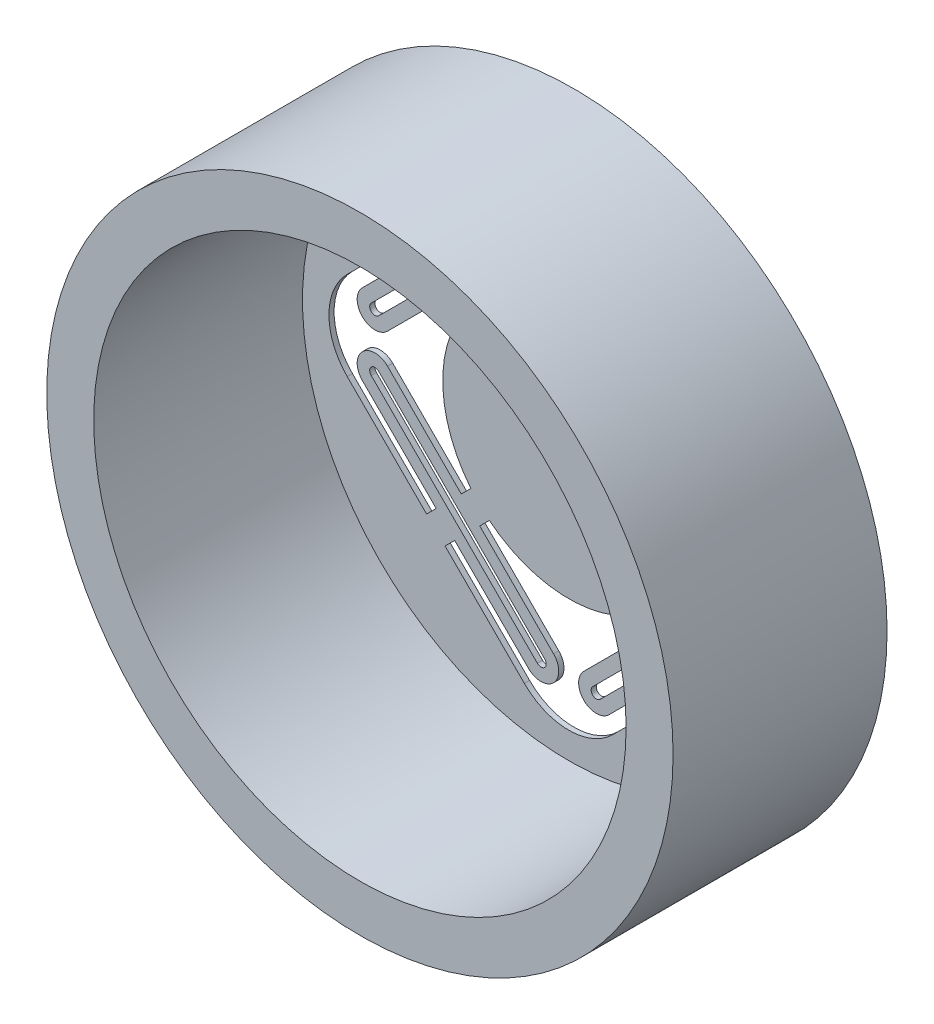
from build123d import *

# Parameters (mm, degrees)
SKETCH1_R           = 15
SKETCH1_R_2         = 12.75
BOSS_EXTRUDE1_DEPTH = 10
SKETCH2_R           = 15
BOSS_EXTRUDE2_DEPTH = 0.25
FILLET1_R           = 3


with BuildPart() as part:
    # Sketch1 → Boss-Extrude1 (new body)
    with BuildSketch(Plane.XY):
        Circle(SKETCH1_R)
        Circle(SKETCH1_R_2, mode=Mode.SUBTRACT)
    extrude(amount=BOSS_EXTRUDE1_DEPTH)

    # Sketch2 → Boss-Extrude2 (add)
    with BuildSketch(Plane.XY):
        Circle(SKETCH2_R)
        with BuildLine():
            Line((5.922042758, 5.03811235), (5.03811235, 5.922042758))
            Line((5.03811235, 5.922042758), (1.502578444, 9.457576664))
            ThreePointArc((1.502578444, 9.457576664), (1.149025054, 9.457576664), (1.149025054, 9.104023274))
            Line((1.149025054, 9.104023274), (4.684558959, 5.568489368))
            Line((4.684558959, 5.568489368), (5.568489368, 4.684558959))
            Line((5.568489368, 4.684558959), (9.104023274, 1.149025054))
            ThreePointArc((9.104023274, 1.149025054), (9.457576664, 1.149025054), (9.457576664, 1.502578444))
            Line((9.457576664, 1.502578444), (5.922042758, 5.03811235))
        make_face(mode=Mode.SUBTRACT)
        with BuildLine():
            Line((6.346306827, 5.462376419), (9.881840733, 1.926842513))
            ThreePointArc((9.881840733, 1.926842513), (9.881840733, 0.724760985), (8.679759205, 0.724760985))
            Line((8.679759205, 0.724760985), (5.144225299, 4.260294891))
            Line((5.144225299, 4.260294891), (4.684605891, 3.800675483))
            ThreePointArc((4.684605891, 3.800675483), (6.032467694, 0), (4.684605891, -3.800675483))
            Line((4.684605891, -3.800675483), (5.144225299, -4.260294891))
            Line((5.144225299, -4.260294891), (8.679759205, -0.724760985))
            ThreePointArc((8.679759205, -0.724760985), (9.881840733, -0.724760985), (9.881840733, -1.926842513))
            Line((9.881840733, -1.926842513), (6.346306827, -5.462376419))
            Line((6.346306827, -5.462376419), (6.805926235, -5.921995827))
            Line((6.805926235, -5.921995827), (12.727922061, 0))
            Line((12.727922061, 0), (6.805926235, 5.921995827))
            Line((6.805926235, 5.921995827), (6.346306827, 5.462376419))
        make_face(mode=Mode.SUBTRACT)
        with BuildLine():
            Line((5.462376419, 6.346306827), (1.926842513, 9.881840733))
            ThreePointArc((1.926842513, 9.881840733), (0.724760985, 9.881840733), (0.724760985, 8.679759205))
            Line((0.724760985, 8.679759205), (4.260294891, 5.144225299))
            Line((4.260294891, 5.144225299), (3.800675483, 4.684605891))
            ThreePointArc((3.800675483, 4.684605891), (0, 6.032467694), (-3.800675483, 4.684605891))
            Line((-3.800675483, 4.684605891), (-4.260294891, 5.144225299))
            Line((-4.260294891, 5.144225299), (-0.724760985, 8.679759205))
            ThreePointArc((-0.724760985, 8.679759205), (-0.724760985, 9.881840733), (-1.926842513, 9.881840733))
            Line((-1.926842513, 9.881840733), (-5.462376419, 6.346306827))
            Line((-5.462376419, 6.346306827), (-5.921995827, 6.805926235))
            Line((-5.921995827, 6.805926235), (0, 12.727922061))
            Line((0, 12.727922061), (5.921995827, 6.805926235))
            Line((5.921995827, 6.805926235), (5.462376419, 6.346306827))
        make_face(mode=Mode.SUBTRACT)
        with BuildLine():
            Line((-5.568489368, 4.684558959), (-9.104023274, 1.149025054))
            ThreePointArc((-9.104023274, 1.149025054), (-9.457576664, 1.149025054), (-9.457576664, 1.502578444))
            Line((-9.457576664, 1.502578444), (-5.922042758, 5.03811235))
            Line((-5.922042758, 5.03811235), (-5.03811235, 5.922042758))
            Line((-5.03811235, 5.922042758), (-1.502578444, 9.457576664))
            ThreePointArc((-1.502578444, 9.457576664), (-1.149025054, 9.457576664), (-1.149025054, 9.104023274))
            Line((-1.149025054, 9.104023274), (-4.684558959, 5.568489368))
            Line((-4.684558959, 5.568489368), (-5.568489368, 4.684558959))
        make_face(mode=Mode.SUBTRACT)
        with BuildLine():
            Line((-6.346306827, 5.462376419), (-6.805926235, 5.921995827))
            Line((-6.805926235, 5.921995827), (-12.727922061, 0))
            Line((-12.727922061, 0), (-6.805926235, -5.921995827))
            Line((-6.805926235, -5.921995827), (-6.346306827, -5.462376419))
            Line((-6.346306827, -5.462376419), (-9.881840733, -1.926842513))
            ThreePointArc((-9.881840733, -1.926842513), (-9.881840733, -0.724760985), (-8.679759205, -0.724760985))
            Line((-8.679759205, -0.724760985), (-5.144225299, -4.260294891))
            Line((-5.144225299, -4.260294891), (-4.684605891, -3.800675483))
            ThreePointArc((-4.684605891, -3.800675483), (-6.032467694, 0), (-4.684605891, 3.800675483))
            Line((-4.684605891, 3.800675483), (-5.144225299, 4.260294891))
            Line((-5.144225299, 4.260294891), (-8.679759205, 0.724760985))
            ThreePointArc((-8.679759205, 0.724760985), (-9.881840733, 0.724760985), (-9.881840733, 1.926842513))
            Line((-9.881840733, 1.926842513), (-6.346306827, 5.462376419))
        make_face(mode=Mode.SUBTRACT)
        with BuildLine():
            Line((5.462376419, -6.346306827), (5.921995827, -6.805926235))
            Line((5.921995827, -6.805926235), (0, -12.727922061))
            Line((0, -12.727922061), (-5.921995827, -6.805926235))
            Line((-5.921995827, -6.805926235), (-5.462376419, -6.346306827))
            Line((-5.462376419, -6.346306827), (-1.926842513, -9.881840733))
            ThreePointArc((-1.926842513, -9.881840733), (-0.724760985, -9.881840733), (-0.724760985, -8.679759205))
            Line((-0.724760985, -8.679759205), (-4.260294891, -5.144225299))
            Line((-4.260294891, -5.144225299), (-3.800675483, -4.684605891))
            ThreePointArc((-3.800675483, -4.684605891), (0, -6.032467694), (3.800675483, -4.684605891))
            Line((3.800675483, -4.684605891), (4.260294891, -5.144225299))
            Line((4.260294891, -5.144225299), (0.724760985, -8.679759205))
            ThreePointArc((0.724760985, -8.679759205), (0.724760985, -9.881840733), (1.926842513, -9.881840733))
            Line((1.926842513, -9.881840733), (5.462376419, -6.346306827))
        make_face(mode=Mode.SUBTRACT)
        with BuildLine():
            Line((5.568489368, -4.684558959), (9.104023274, -1.149025054))
            ThreePointArc((9.104023274, -1.149025054), (9.457576664, -1.149025054), (9.457576664, -1.502578444))
            Line((9.457576664, -1.502578444), (5.922042758, -5.03811235))
            Line((5.922042758, -5.03811235), (5.03811235, -5.922042758))
            Line((5.03811235, -5.922042758), (1.502578444, -9.457576664))
            ThreePointArc((1.502578444, -9.457576664), (1.149025054, -9.457576664), (1.149025054, -9.104023274))
            Line((1.149025054, -9.104023274), (4.684558959, -5.568489368))
            Line((4.684558959, -5.568489368), (5.568489368, -4.684558959))
        make_face(mode=Mode.SUBTRACT)
        with BuildLine():
            Line((-5.568489368, -4.684558959), (-4.684558959, -5.568489368))
            Line((-4.684558959, -5.568489368), (-1.149025054, -9.104023274))
            ThreePointArc((-1.149025054, -9.104023274), (-1.149025054, -9.457576664), (-1.502578444, -9.457576664))
            Line((-1.502578444, -9.457576664), (-5.03811235, -5.922042758))
            Line((-5.03811235, -5.922042758), (-5.922042758, -5.03811235))
            Line((-5.922042758, -5.03811235), (-9.457576664, -1.502578444))
            ThreePointArc((-9.457576664, -1.502578444), (-9.457576664, -1.149025054), (-9.104023274, -1.149025054))
            Line((-9.104023274, -1.149025054), (-5.568489368, -4.684558959))
        make_face(mode=Mode.SUBTRACT)
    extrude(amount=-BOSS_EXTRUDE2_DEPTH)

    # Fillet1
    fillet1_edges = [part.edges().sort_by_distance(p)[0] for p in [
        (0, -12.727922061, -0.125),
        (-12.727922061, 0, -0.125),
        (0, 12.727922061, -0.125),
        (12.727922061, 0, -0.125),
    ]]
    fillet(fillet1_edges, radius=FILLET1_R)


solid = part.part
